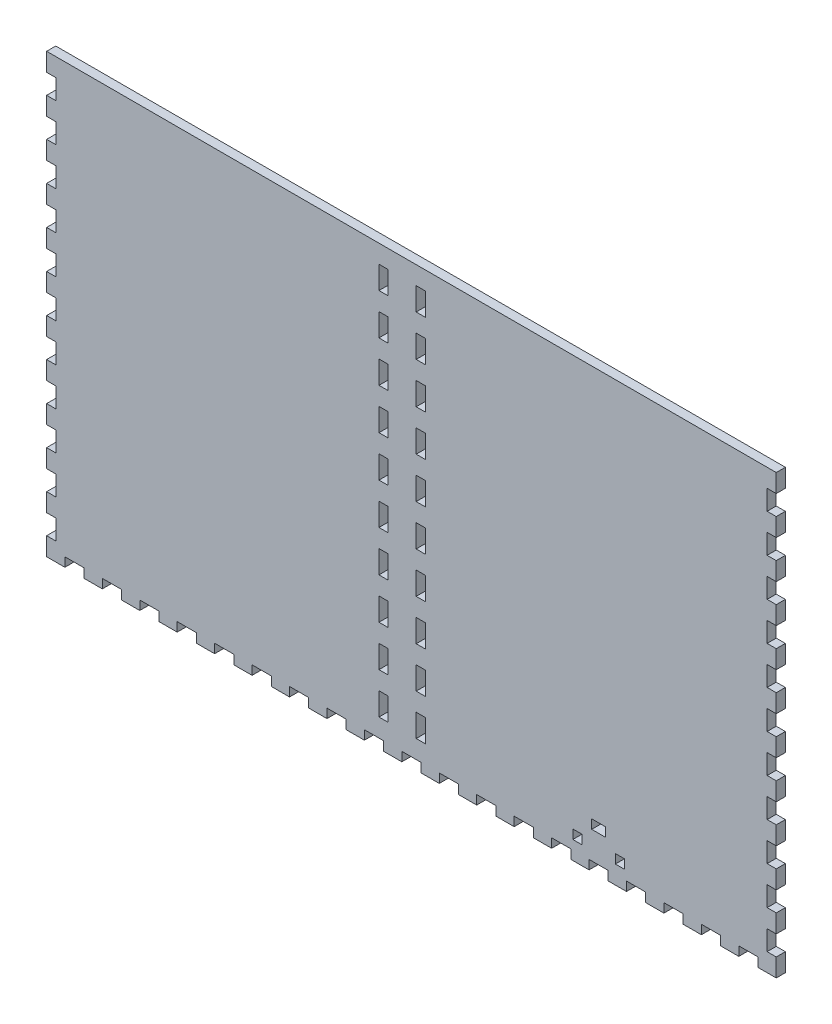
from build123d import *

# Parameters (mm, degrees)
SKETCH1_W           = 508
SKETCH1_H           = 190.5
BOSS_EXTRUDE1_DEPTH = 6.35
SKETCH2_W           = 508
SKETCH2_H           = 190.5
SKETCH2_W_2         = 495.3
SKETCH2_H_2         = 177.8
BOSS_EXTRUDE2_DEPTH = 298.45
SKETCH3_W           = 6.35
SKETCH3_H           = 16.933333333
SKETCH3_H_2         = 16.933333334
CUT_EXTRUDE1_DEPTH  = 12.7
SKETCH4_W           = 6.35
SKETCH4_H           = 15.875
CUT_EXTRUDE2_DEPTH  = 6.35
SKETCH6_W           = 538.010552984
SKETCH6_H           = 185.512805236
CUT_EXTRUDE5_DEPTH  = 305.8
SKETCH5_W           = 13.368421053
SKETCH5_H           = 6.35
SKETCH5_W_2         = 13.368421052
CUT_EXTRUDE6_DEPTH  = 6.35
SKETCH7_W           = 6.35
SKETCH7_H           = 13.854545455
SKETCH7_H_2         = 13.854545454
CUT_EXTRUDE8_DEPTH  = 6.35
SKETCH8_W           = 9.652
SKETCH8_H           = 6.35
SKETCH8_W_2         = 6.35
LEVER_HOLE_DEPTH    = 7.35


with BuildPart() as part:
    # Sketch1 → Boss-Extrude1 (new body)
    with BuildSketch(Plane(origin=(0, 0, 0), x_dir=(1, 0, 0), z_dir=(0, 1, 0))):
        Rectangle(SKETCH1_W, SKETCH1_H)
    extrude(amount=BOSS_EXTRUDE1_DEPTH)

    # Sketch2 → Boss-Extrude2 (add)
    with BuildSketch(Plane(origin=(0, 6.35, 0), x_dir=(1, 0, 0), z_dir=(0, 1, 0))):
        Rectangle(SKETCH2_W, SKETCH2_H)
        Rectangle(SKETCH2_W_2, SKETCH2_H_2, mode=Mode.SUBTRACT)
    extrude(amount=BOSS_EXTRUDE2_DEPTH)

    # Sketch3 → Cut-Extrude1 (cut)
    with BuildSketch(Plane.XY.offset(95.25)):
        with BuildLine():
            Line((-3.302, 283.21), (-3.302, 6.35))
            Line((-3.302, 6.35), (3.302, 6.35))
            Line((3.302, 6.35), (3.302, 292.354))
            Line((3.302, 292.354), (-16.256, 292.354))
            Line((-16.256, 292.354), (-16.256, 285.75))
            Line((-16.256, 285.75), (-5.842, 285.75))
            ThreePointArc((-5.842, 285.75), (-4.045948776, 285.006051224), (-3.302, 283.21))
        make_face()
        with Locations((12.827, 80.433333334)):
            Rectangle(SKETCH3_W, SKETCH3_H)
        with Locations((12.827, 50.8)):
            Rectangle(SKETCH3_W, SKETCH3_H_2)
        with Locations((12.827, 21.166666667)):
            Rectangle(SKETCH3_W, SKETCH3_H)
    extrude(amount=-CUT_EXTRUDE1_DEPTH, mode=Mode.SUBTRACT)

    # Sketch4 → Cut-Extrude2 (cut)
    with BuildSketch(Plane.XY.offset(-88.9)):
        with Locations((-19.431, 284.1625)):
            Rectangle(SKETCH4_W, SKETCH4_H)
        with Locations((-19.431, 255.5875)):
            Rectangle(SKETCH4_W, SKETCH4_H)
        with Locations((-19.431, 227.0125)):
            Rectangle(SKETCH4_W, SKETCH4_H)
        with Locations((-19.431, 198.4375)):
            Rectangle(SKETCH4_W, SKETCH4_H)
        with Locations((-19.431, 169.8625)):
            Rectangle(SKETCH4_W, SKETCH4_H)
        with Locations((-19.431, 141.2875)):
            Rectangle(SKETCH4_W, SKETCH4_H)
        with Locations((-19.431, 112.7125)):
            Rectangle(SKETCH4_W, SKETCH4_H)
        with Locations((-19.431, 84.1375)):
            Rectangle(SKETCH4_W, SKETCH4_H)
        with Locations((-19.431, 55.5625)):
            Rectangle(SKETCH4_W, SKETCH4_H)
        with Locations((-19.431, 26.9875)):
            Rectangle(SKETCH4_W, SKETCH4_H)
    cut_extrude2 = extrude(amount=-CUT_EXTRUDE2_DEPTH, mode=Mode.SUBTRACT)

    # Mirror1: Cut-Extrude2 across plane
    add(cut_extrude2.mirror(Plane.ZY.offset(6.477)), mode=Mode.SUBTRACT)

    # Sketch6 → Cut-Extrude5 (cut, through all)
    with BuildSketch(Plane(origin=(0, 0, 0), x_dir=(1, 0, 0), z_dir=(0, 1, 0))):
        with Locations((8.602966584, -3.856402618)):
            Rectangle(SKETCH6_W, SKETCH6_H)
    extrude(amount=CUT_EXTRUDE5_DEPTH, mode=Mode.SUBTRACT)

    # Sketch5 → Cut-Extrude6 (cut)
    with BuildSketch(Plane(origin=(0, 0, 0), x_dir=(-1, 0, 0), z_dir=(0, -1, 0))):
        with Locations((-234.615789474, 92.075)):
            Rectangle(SKETCH5_W, SKETCH5_H)
        with Locations((-208.547368421, 92.075)):
            Rectangle(SKETCH5_W_2, SKETCH5_H)
        with Locations((-182.478947369, 92.075)):
            Rectangle(SKETCH5_W, SKETCH5_H)
        with Locations((-156.410526316, 92.075)):
            Rectangle(SKETCH5_W, SKETCH5_H)
        with Locations((-130.342105263, 92.075)):
            Rectangle(SKETCH5_W_2, SKETCH5_H)
        with Locations((-104.273684211, 92.075)):
            Rectangle(SKETCH5_W, SKETCH5_H)
        with Locations((-78.205263158, 92.075)):
            Rectangle(SKETCH5_W_2, SKETCH5_H)
        with Locations((-52.136842106, 92.075)):
            Rectangle(SKETCH5_W, SKETCH5_H)
        with Locations((-26.068421052, 92.075)):
            Rectangle(SKETCH5_W, SKETCH5_H)
        with Locations((0, 92.075)):
            Rectangle(SKETCH5_W_2, SKETCH5_H)
        with Locations((26.068421052, 92.075)):
            Rectangle(SKETCH5_W, SKETCH5_H)
        with Locations((52.136842106, 92.075)):
            Rectangle(SKETCH5_W, SKETCH5_H)
        with Locations((78.205263158, 92.075)):
            Rectangle(SKETCH5_W_2, SKETCH5_H)
        with Locations((104.273684211, 92.075)):
            Rectangle(SKETCH5_W, SKETCH5_H)
        with Locations((130.342105263, 92.075)):
            Rectangle(SKETCH5_W_2, SKETCH5_H)
        with Locations((156.410526316, 92.075)):
            Rectangle(SKETCH5_W, SKETCH5_H)
        with Locations((182.478947369, 92.075)):
            Rectangle(SKETCH5_W, SKETCH5_H)
        with Locations((208.547368421, 92.075)):
            Rectangle(SKETCH5_W_2, SKETCH5_H)
        with Locations((234.615789474, 92.075)):
            Rectangle(SKETCH5_W, SKETCH5_H)
    extrude(amount=-CUT_EXTRUDE6_DEPTH, mode=Mode.SUBTRACT)

    # Sketch7 → Cut-Extrude8 (cut)
    with BuildSketch(Plane.ZY.offset(254)):
        with Locations((-92.075, 285.172727273)):
            Rectangle(SKETCH7_W, SKETCH7_H)
        with Locations((-92.075, 258.618181818)):
            Rectangle(SKETCH7_W, SKETCH7_H_2)
        with Locations((-92.075, 232.063636364)):
            Rectangle(SKETCH7_W, SKETCH7_H)
        with Locations((-92.075, 205.509090909)):
            Rectangle(SKETCH7_W, SKETCH7_H_2)
        with Locations((-92.075, 178.954545455)):
            Rectangle(SKETCH7_W, SKETCH7_H)
        with Locations((-92.075, 152.4)):
            Rectangle(SKETCH7_W, SKETCH7_H_2)
        with Locations((-92.075, 125.845454546)):
            Rectangle(SKETCH7_W, SKETCH7_H)
        with Locations((-92.075, 99.290909091)):
            Rectangle(SKETCH7_W, SKETCH7_H_2)
        with Locations((-92.075, 72.736363637)):
            Rectangle(SKETCH7_W, SKETCH7_H)
        with Locations((-92.075, 46.181818182)):
            Rectangle(SKETCH7_W, SKETCH7_H_2)
        with Locations((-92.075, 19.627272728)):
            Rectangle(SKETCH7_W, SKETCH7_H)
    cut_extrude8 = extrude(amount=-CUT_EXTRUDE8_DEPTH, mode=Mode.SUBTRACT)

    # Mirror2: Cut-Extrude8 across plane
    add(cut_extrude8.mirror(Plane(origin=(0, 0, 0), x_dir=(0, 0, 1), z_dir=(1, 0, 0))), mode=Mode.SUBTRACT)

    # Sketch8 → Lever Hole (cut, through all)
    with BuildSketch(Plane(origin=(0, 0, -95.25), x_dir=(-1, 0, 0), z_dir=(0, 0, -1))):
        with Locations((-130.342105263, 28.575)):
            Rectangle(SKETCH8_W, SKETCH8_H)
        with Locations((-145.137605263, 15.875)):
            Rectangle(SKETCH8_W_2, SKETCH8_H)
        with Locations((-115.546605263, 15.875)):
            Rectangle(SKETCH8_W_2, SKETCH8_H)
    extrude(amount=-LEVER_HOLE_DEPTH, mode=Mode.SUBTRACT)


solid = part.part
